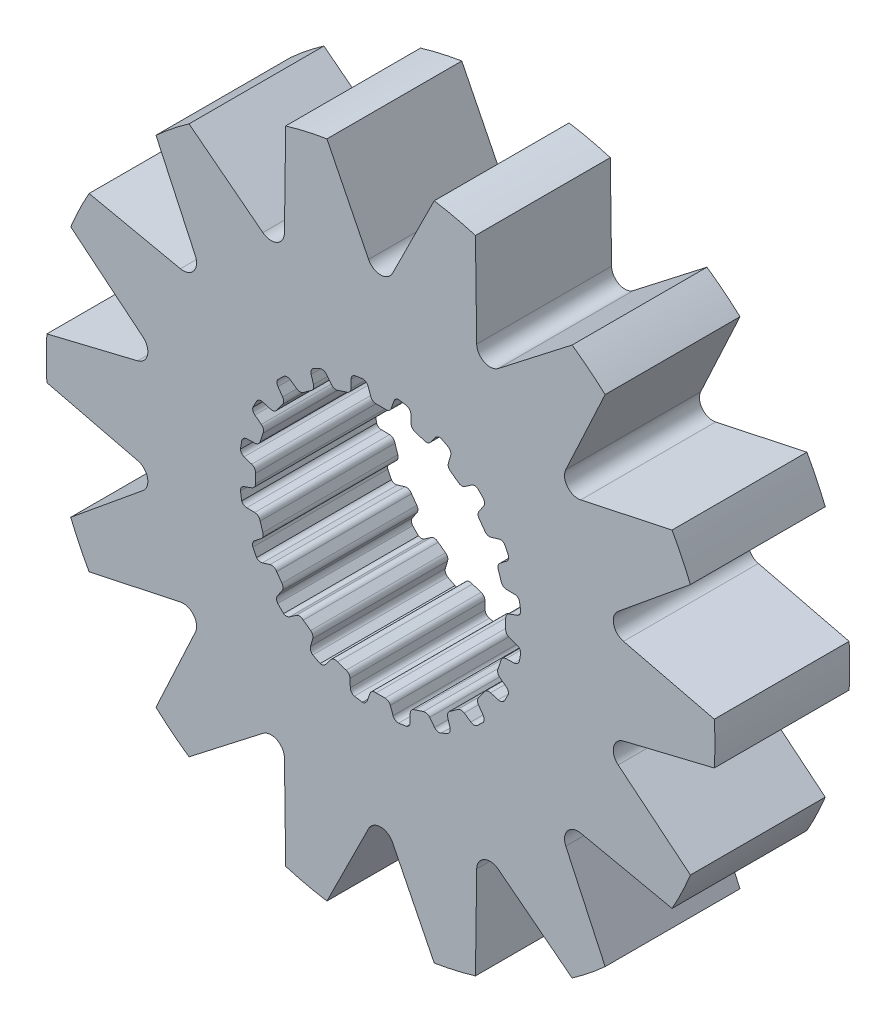
from build123d import *

# Parameters (mm, degrees)
SKETCH1_R           = 7.934400625
BOSS_EXTRUDE1_DEPTH = 1.6002
CUT_EXTRUDE1_DEPTH  = 3.2004


with BuildPart() as part:
    # Sketch1 → Boss-Extrude1 (new body, symmetric)
    with BuildSketch(Plane.XY):
        Circle(SKETCH1_R)
        with BuildLine():
            Line((-0.106949245, 2.969874934), (0.106949245, 2.969874934))
            ThreePointArc((0.106949245, 2.969874934), (0.196343213, 2.986924176), (0.253739238, 3.057547504))
            Line((0.253739238, 3.057547504), (0.315888147, 3.237526941))
            ThreePointArc((0.315888147, 3.237526941), (0.359032156, 3.298322911), (0.4281449, 3.326269005))
            Line((0.4281449, 3.326269005), (0.620027588, 3.2937547))
            ThreePointArc((0.620027588, 3.2937547), (0.689621142, 3.24802576), (0.718272212, 3.169836791))
            Line((0.718272212, 3.169836791), (0.724389167, 2.979527391))
            ThreePointArc((0.724389167, 2.979527391), (0.750934762, 2.9040661), (0.816027049, 2.857568043))
            Line((0.816027049, 2.857568043), (1.019456602, 2.791469774))
            ThreePointArc((1.019456602, 2.791469774), (1.109743823, 2.780060312), (1.186154496, 2.829490741))
            Line((1.186154496, 2.829490741), (1.300878326, 2.981456288))
            ThreePointArc((1.300878326, 2.981456288), (1.360697704, 3.02594446), (1.435063648, 3.031165762))
            Line((1.435063648, 3.031165762), (1.607507455, 2.940947809))
            ThreePointArc((1.607507455, 2.940947809), (1.659563839, 2.875951412), (1.662650905, 2.792735615))
            Line((1.662650905, 2.792735615), (1.609659636, 2.609850378))
            ThreePointArc((1.609659636, 2.609850378), (1.611587176, 2.529879385), (1.659124931, 2.465542482))
            Line((1.659124931, 2.465542482), (1.832172444, 2.339816104))
            ThreePointArc((1.832172444, 2.339816104), (1.914514976, 2.301064775), (2.002460687, 2.32446371))
            Line((2.002460687, 2.32446371), (2.158529469, 2.433539921))
            ThreePointArc((2.158529469, 2.433539921), (2.229168681, 2.457365482), (2.301508367, 2.439350895))
            Line((2.301508367, 2.439350895), (2.437633293, 2.300260456))
            ThreePointArc((2.437633293, 2.300260456), (2.467056864, 2.222358901), (2.444277744, 2.14226202))
            Line((2.444277744, 2.14226202), (2.337365406, 1.984703026))
            ThreePointArc((2.337365406, 1.984703026), (2.314486209, 1.908050449), (2.339816104, 1.832172444))
            Line((2.339816104, 1.832172444), (2.465542482, 1.659124931))
            ThreePointArc((2.465542482, 1.659124931), (2.531880064, 1.596824985), (2.622752074, 1.591901975))
            Line((2.622752074, 1.591901975), (2.804888709, 1.64741171))
            ThreePointArc((2.804888709, 1.64741171), (2.879433095, 1.648242449), (2.942665411, 1.608755366))
            Line((2.942665411, 1.608755366), (3.0291466, 1.434407582))
            ThreePointArc((3.0291466, 1.434407582), (3.033057175, 1.351226417), (2.986641646, 1.282088892))
            Line((2.986641646, 1.282088892), (2.836273564, 1.165279113))
            ThreePointArc((2.836273564, 1.165279113), (2.790827206, 1.099448241), (2.791469774, 1.019456602))
            Line((2.791469774, 1.019456602), (2.857568043, 0.816027049))
            ThreePointArc((2.857568043, 0.816027049), (2.901407091, 0.736276839), (2.986310214, 0.703513784))
            Line((2.986310214, 0.703513784), (3.1766859, 0.700023363))
            ThreePointArc((3.1766859, 0.700023363), (3.247838536, 0.677777961), (3.295773863, 0.620683653))
            Line((3.295773863, 0.620683653), (3.324145932, 0.4281449))
            ThreePointArc((3.324145932, 0.4281449), (3.302160717, 0.347826477), (3.236652255, 0.29641597))
            Line((3.236652255, 0.29641597), (3.057547504, 0.231789562))
            ThreePointArc((3.057547504, 0.231789562), (2.993982591, 0.183224379), (2.969874934, 0.106949245))
            Line((2.969874934, 0.106949245), (2.969874934, -0.106949245))
            ThreePointArc((2.969874934, -0.106949245), (2.986924176, -0.196343213), (3.057547504, -0.253739238))
            Line((3.057547504, -0.253739238), (3.237526941, -0.315888147))
            ThreePointArc((3.237526941, -0.315888147), (3.298322911, -0.359032156), (3.326269005, -0.4281449))
            Line((3.326269005, -0.4281449), (3.2937547, -0.620027588))
            ThreePointArc((3.2937547, -0.620027588), (3.24802576, -0.689621142), (3.169836791, -0.718272212))
            Line((3.169836791, -0.718272212), (2.979527391, -0.724389167))
            ThreePointArc((2.979527391, -0.724389167), (2.9040661, -0.750934762), (2.857568043, -0.816027049))
            Line((2.857568043, -0.816027049), (2.791469774, -1.019456602))
            ThreePointArc((2.791469774, -1.019456602), (2.780060312, -1.109743823), (2.829490741, -1.186154496))
            Line((2.829490741, -1.186154496), (2.981456288, -1.300878326))
            ThreePointArc((2.981456288, -1.300878326), (3.02594446, -1.360697704), (3.031165762, -1.435063648))
            Line((3.031165762, -1.435063648), (2.940947809, -1.607507455))
            ThreePointArc((2.940947809, -1.607507455), (2.875951412, -1.659563839), (2.792735615, -1.662650905))
            Line((2.792735615, -1.662650905), (2.609850378, -1.609659636))
            ThreePointArc((2.609850378, -1.609659636), (2.529879385, -1.611587176), (2.465542482, -1.659124931))
            Line((2.465542482, -1.659124931), (2.339816104, -1.832172444))
            ThreePointArc((2.339816104, -1.832172444), (2.301064775, -1.914514976), (2.32446371, -2.002460687))
            Line((2.32446371, -2.002460687), (2.433539921, -2.158529469))
            ThreePointArc((2.433539921, -2.158529469), (2.457365482, -2.229168681), (2.439350895, -2.301508367))
            Line((2.439350895, -2.301508367), (2.300260456, -2.437633293))
            ThreePointArc((2.300260456, -2.437633293), (2.222358901, -2.467056864), (2.14226202, -2.444277744))
            Line((2.14226202, -2.444277744), (1.984703026, -2.337365406))
            ThreePointArc((1.984703026, -2.337365406), (1.908050449, -2.314486209), (1.832172444, -2.339816104))
            Line((1.832172444, -2.339816104), (1.659124931, -2.465542482))
            ThreePointArc((1.659124931, -2.465542482), (1.596824985, -2.531880064), (1.591901975, -2.622752074))
            Line((1.591901975, -2.622752074), (1.64741171, -2.804888709))
            ThreePointArc((1.64741171, -2.804888709), (1.648242449, -2.879433095), (1.608755366, -2.942665411))
            Line((1.608755366, -2.942665411), (1.434407582, -3.0291466))
            ThreePointArc((1.434407582, -3.0291466), (1.351226417, -3.033057175), (1.282088892, -2.986641646))
            Line((1.282088892, -2.986641646), (1.165279113, -2.836273564))
            ThreePointArc((1.165279113, -2.836273564), (1.099448241, -2.790827206), (1.019456602, -2.791469774))
            Line((1.019456602, -2.791469774), (0.816027049, -2.857568043))
            ThreePointArc((0.816027049, -2.857568043), (0.736276839, -2.901407091), (0.703513784, -2.986310214))
            Line((0.703513784, -2.986310214), (0.700023363, -3.1766859))
            ThreePointArc((0.700023363, -3.1766859), (0.677777961, -3.247838536), (0.620683653, -3.295773863))
            Line((0.620683653, -3.295773863), (0.4281449, -3.324145932))
            ThreePointArc((0.4281449, -3.324145932), (0.347826477, -3.302160717), (0.29641597, -3.236652255))
            Line((0.29641597, -3.236652255), (0.231789562, -3.057547504))
            ThreePointArc((0.231789562, -3.057547504), (0.183224379, -2.993982591), (0.106949245, -2.969874934))
            Line((0.106949245, -2.969874934), (-0.106949245, -2.969874934))
            ThreePointArc((-0.106949245, -2.969874934), (-0.196343213, -2.986924176), (-0.253739238, -3.057547504))
            Line((-0.253739238, -3.057547504), (-0.315888147, -3.237526941))
            ThreePointArc((-0.315888147, -3.237526941), (-0.359032156, -3.298322911), (-0.4281449, -3.326269005))
            Line((-0.4281449, -3.326269005), (-0.620027588, -3.2937547))
            ThreePointArc((-0.620027588, -3.2937547), (-0.689621142, -3.24802576), (-0.718272212, -3.169836791))
            Line((-0.718272212, -3.169836791), (-0.724389167, -2.979527391))
            ThreePointArc((-0.724389167, -2.979527391), (-0.750934762, -2.9040661), (-0.816027049, -2.857568043))
            Line((-0.816027049, -2.857568043), (-1.019456602, -2.791469774))
            ThreePointArc((-1.019456602, -2.791469774), (-1.109743823, -2.780060312), (-1.186154496, -2.829490741))
            Line((-1.186154496, -2.829490741), (-1.300878326, -2.981456288))
            ThreePointArc((-1.300878326, -2.981456288), (-1.360697704, -3.02594446), (-1.435063648, -3.031165762))
            Line((-1.435063648, -3.031165762), (-1.607507455, -2.940947809))
            ThreePointArc((-1.607507455, -2.940947809), (-1.659563839, -2.875951412), (-1.662650905, -2.792735615))
            Line((-1.662650905, -2.792735615), (-1.609659636, -2.609850378))
            ThreePointArc((-1.609659636, -2.609850378), (-1.611587176, -2.529879385), (-1.659124931, -2.465542482))
            Line((-1.659124931, -2.465542482), (-1.832172444, -2.339816104))
            ThreePointArc((-1.832172444, -2.339816104), (-1.914514976, -2.301064775), (-2.002460687, -2.32446371))
            Line((-2.002460687, -2.32446371), (-2.158529469, -2.433539921))
            ThreePointArc((-2.158529469, -2.433539921), (-2.229168681, -2.457365482), (-2.301508367, -2.439350895))
            Line((-2.301508367, -2.439350895), (-2.437633293, -2.300260456))
            ThreePointArc((-2.437633293, -2.300260456), (-2.467056864, -2.222358901), (-2.444277744, -2.14226202))
            Line((-2.444277744, -2.14226202), (-2.337365406, -1.984703026))
            ThreePointArc((-2.337365406, -1.984703026), (-2.314486209, -1.908050449), (-2.339816104, -1.832172444))
            Line((-2.339816104, -1.832172444), (-2.465542482, -1.659124931))
            ThreePointArc((-2.465542482, -1.659124931), (-2.531880064, -1.596824985), (-2.622752074, -1.591901975))
            Line((-2.622752074, -1.591901975), (-2.804888709, -1.64741171))
            ThreePointArc((-2.804888709, -1.64741171), (-2.879433095, -1.648242449), (-2.942665411, -1.608755366))
            Line((-2.942665411, -1.608755366), (-3.0291466, -1.434407582))
            ThreePointArc((-3.0291466, -1.434407582), (-3.033057175, -1.351226417), (-2.986641646, -1.282088892))
            Line((-2.986641646, -1.282088892), (-2.836273564, -1.165279113))
            ThreePointArc((-2.836273564, -1.165279113), (-2.790827206, -1.099448241), (-2.791469774, -1.019456602))
            Line((-2.791469774, -1.019456602), (-2.857568043, -0.816027049))
            ThreePointArc((-2.857568043, -0.816027049), (-2.901407091, -0.736276839), (-2.986310214, -0.703513784))
            Line((-2.986310214, -0.703513784), (-3.1766859, -0.700023363))
            ThreePointArc((-3.1766859, -0.700023363), (-3.247838536, -0.677777961), (-3.295773863, -0.620683653))
            Line((-3.295773863, -0.620683653), (-3.324145932, -0.4281449))
            ThreePointArc((-3.324145932, -0.4281449), (-3.302160717, -0.347826477), (-3.236652255, -0.29641597))
            Line((-3.236652255, -0.29641597), (-3.057547504, -0.231789562))
            ThreePointArc((-3.057547504, -0.231789562), (-2.993982591, -0.183224379), (-2.969874934, -0.106949245))
            Line((-2.969874934, -0.106949245), (-2.969874934, 0.106949245))
            ThreePointArc((-2.969874934, 0.106949245), (-2.986924176, 0.196343213), (-3.057547504, 0.253739238))
            Line((-3.057547504, 0.253739238), (-3.237526941, 0.315888147))
            ThreePointArc((-3.237526941, 0.315888147), (-3.298322911, 0.359032156), (-3.326269005, 0.4281449))
            Line((-3.326269005, 0.4281449), (-3.2937547, 0.620027588))
            ThreePointArc((-3.2937547, 0.620027588), (-3.24802576, 0.689621142), (-3.169836791, 0.718272212))
            Line((-3.169836791, 0.718272212), (-2.979527391, 0.724389167))
            ThreePointArc((-2.979527391, 0.724389167), (-2.9040661, 0.750934762), (-2.857568043, 0.816027049))
            Line((-2.857568043, 0.816027049), (-2.791469774, 1.019456602))
            ThreePointArc((-2.791469774, 1.019456602), (-2.780060312, 1.109743823), (-2.829490741, 1.186154496))
            Line((-2.829490741, 1.186154496), (-2.981456288, 1.300878326))
            ThreePointArc((-2.981456288, 1.300878326), (-3.02594446, 1.360697704), (-3.031165762, 1.435063648))
            Line((-3.031165762, 1.435063648), (-2.940947809, 1.607507455))
            ThreePointArc((-2.940947809, 1.607507455), (-2.875951412, 1.659563839), (-2.792735615, 1.662650905))
            Line((-2.792735615, 1.662650905), (-2.609850378, 1.609659636))
            ThreePointArc((-2.609850378, 1.609659636), (-2.529879385, 1.611587176), (-2.465542482, 1.659124931))
            Line((-2.465542482, 1.659124931), (-2.339816104, 1.832172444))
            ThreePointArc((-2.339816104, 1.832172444), (-2.301064775, 1.914514976), (-2.32446371, 2.002460687))
            Line((-2.32446371, 2.002460687), (-2.433539921, 2.158529469))
            ThreePointArc((-2.433539921, 2.158529469), (-2.457365482, 2.229168681), (-2.439350895, 2.301508367))
            Line((-2.439350895, 2.301508367), (-2.300260456, 2.437633293))
            ThreePointArc((-2.300260456, 2.437633293), (-2.222358901, 2.467056864), (-2.14226202, 2.444277744))
            Line((-2.14226202, 2.444277744), (-1.984703026, 2.337365406))
            ThreePointArc((-1.984703026, 2.337365406), (-1.908050449, 2.314486209), (-1.832172444, 2.339816104))
            Line((-1.832172444, 2.339816104), (-1.659124931, 2.465542482))
            ThreePointArc((-1.659124931, 2.465542482), (-1.596824985, 2.531880064), (-1.591901975, 2.622752074))
            Line((-1.591901975, 2.622752074), (-1.64741171, 2.804888709))
            ThreePointArc((-1.64741171, 2.804888709), (-1.648242449, 2.879433095), (-1.608755366, 2.942665411))
            Line((-1.608755366, 2.942665411), (-1.434407582, 3.0291466))
            ThreePointArc((-1.434407582, 3.0291466), (-1.351226417, 3.033057175), (-1.282088892, 2.986641646))
            Line((-1.282088892, 2.986641646), (-1.165279113, 2.836273564))
            ThreePointArc((-1.165279113, 2.836273564), (-1.099448241, 2.790827206), (-1.019456602, 2.791469774))
            Line((-1.019456602, 2.791469774), (-0.816027049, 2.857568043))
            ThreePointArc((-0.816027049, 2.857568043), (-0.736276839, 2.901407091), (-0.703513784, 2.986310214))
            Line((-0.703513784, 2.986310214), (-0.700023363, 3.1766859))
            ThreePointArc((-0.700023363, 3.1766859), (-0.677777961, 3.247838536), (-0.620683653, 3.295773863))
            Line((-0.620683653, 3.295773863), (-0.4281449, 3.324145932))
            ThreePointArc((-0.4281449, 3.324145932), (-0.347826477, 3.302160717), (-0.29641597, 3.236652255))
            Line((-0.29641597, 3.236652255), (-0.231789562, 3.057547504))
            ThreePointArc((-0.231789562, 3.057547504), (-0.183224379, 2.993982591), (-0.106949245, 2.969874934))
        make_face(mode=Mode.SUBTRACT)
    extrude(amount=BOSS_EXTRUDE1_DEPTH, both=True)

    # Sketch2 → Cut-Extrude1 (cut)
    with BuildSketch(Plane.XY.offset(1.6002)):
        with BuildLine():
            Line((-1.272861916, 7.831636854), (-0.284158084, 5.848036698))
            ThreePointArc((-0.284158084, 5.848036698), (0, 5.672171908), (0.284158084, 5.848036698))
            Line((0.284158084, 5.848036698), (1.272861916, 7.831636854))
            ThreePointArc((1.272861916, 7.831636854), (0, 7.934400625), (-1.272861916, 7.831636854))
        make_face()
        with BuildLine():
            Line((4.544828841, 6.503786903), (2.793385616, 5.145607431))
            ThreePointArc((2.793385616, 5.145607431), (2.461063157, 5.110450303), (2.281350442, 5.392190575))
            Line((2.281350442, 5.392190575), (2.251210922, 7.608335078))
            ThreePointArc((2.251210922, 7.608335078), (3.442607411, 7.148647948), (4.544828841, 6.503786903))
        make_face()
        with BuildLine():
            Line((6.916636676, 3.887782192), (4.749348869, 3.424027506))
            ThreePointArc((4.749348869, 3.424027506), (4.434682572, 3.536541339), (4.395009534, 3.868354978))
            Line((4.395009534, 3.868354978), (5.329403828, 5.878109229))
            ThreePointArc((5.329403828, 5.878109229), (6.203364203, 4.947017873), (6.916636676, 3.887782192))
        make_face()
        with BuildLine():
            Line((7.91851979, 0.501754537), (5.764645331, 1.02427694))
            ThreePointArc((5.764645331, 1.02427694), (5.529958716, 1.262176991), (5.638183086, 1.578344235))
            Line((5.638183086, 1.578344235), (7.352042945, 2.983651757))
            ThreePointArc((7.352042945, 2.983651757), (7.735468636, 1.765570237), (7.91851979, 0.501754537))
        make_face()
        with BuildLine():
            Line((7.352042945, -2.983651757), (5.638183086, -1.578344235))
            ThreePointArc((5.638183086, -1.578344235), (5.529958716, -1.262176991), (5.764645331, -1.02427694))
            Line((5.764645331, -1.02427694), (7.91851979, -0.501754537))
            ThreePointArc((7.91851979, -0.501754537), (7.735468636, -1.765570237), (7.352042945, -2.983651757))
        make_face()
        with BuildLine():
            Line((5.329403828, -5.878109229), (4.395009534, -3.868354978))
            ThreePointArc((4.395009534, -3.868354978), (4.434682572, -3.536541339), (4.749348869, -3.424027506))
            Line((4.749348869, -3.424027506), (6.916636676, -3.887782192))
            ThreePointArc((6.916636676, -3.887782192), (6.203364203, -4.947017873), (5.329403828, -5.878109229))
        make_face()
        with BuildLine():
            Line((2.251210922, -7.608335078), (2.281350442, -5.392190575))
            ThreePointArc((2.281350442, -5.392190575), (2.461063157, -5.110450303), (2.793385616, -5.145607431))
            Line((2.793385616, -5.145607431), (4.544828841, -6.503786903))
            ThreePointArc((4.544828841, -6.503786903), (3.442607411, -7.148647948), (2.251210922, -7.608335078))
        make_face()
        with BuildLine():
            Line((-1.272861916, -7.831636854), (-0.284158084, -5.848036698))
            ThreePointArc((-0.284158084, -5.848036698), (0, -5.672171908), (0.284158084, -5.848036698))
            Line((0.284158084, -5.848036698), (1.272861916, -7.831636854))
            ThreePointArc((1.272861916, -7.831636854), (0, -7.934400625), (-1.272861916, -7.831636854))
        make_face()
        with BuildLine():
            Line((-4.544828841, -6.503786903), (-2.793385616, -5.145607431))
            ThreePointArc((-2.793385616, -5.145607431), (-2.461063157, -5.110450303), (-2.281350442, -5.392190575))
            Line((-2.281350442, -5.392190575), (-2.251210922, -7.608335078))
            ThreePointArc((-2.251210922, -7.608335078), (-3.442607411, -7.148647948), (-4.544828841, -6.503786903))
        make_face()
        with BuildLine():
            Line((-6.916636676, -3.887782192), (-4.749348869, -3.424027506))
            ThreePointArc((-4.749348869, -3.424027506), (-4.434682572, -3.536541339), (-4.395009534, -3.868354978))
            Line((-4.395009534, -3.868354978), (-5.329403828, -5.878109229))
            ThreePointArc((-5.329403828, -5.878109229), (-6.203364203, -4.947017873), (-6.916636676, -3.887782192))
        make_face()
        with BuildLine():
            Line((-7.91851979, -0.501754537), (-5.764645331, -1.02427694))
            ThreePointArc((-5.764645331, -1.02427694), (-5.529958716, -1.262176991), (-5.638183086, -1.578344235))
            Line((-5.638183086, -1.578344235), (-7.352042945, -2.983651757))
            ThreePointArc((-7.352042945, -2.983651757), (-7.735468636, -1.765570237), (-7.91851979, -0.501754537))
        make_face()
        with BuildLine():
            Line((-7.352042945, 2.983651757), (-5.638183086, 1.578344235))
            ThreePointArc((-5.638183086, 1.578344235), (-5.529958716, 1.262176991), (-5.764645331, 1.02427694))
            Line((-5.764645331, 1.02427694), (-7.91851979, 0.501754537))
            ThreePointArc((-7.91851979, 0.501754537), (-7.735468636, 1.765570237), (-7.352042945, 2.983651757))
        make_face()
        with BuildLine():
            Line((-5.329403828, 5.878109229), (-4.395009534, 3.868354978))
            ThreePointArc((-4.395009534, 3.868354978), (-4.434682572, 3.536541339), (-4.749348869, 3.424027506))
            Line((-4.749348869, 3.424027506), (-6.916636676, 3.887782192))
            ThreePointArc((-6.916636676, 3.887782192), (-6.203364203, 4.947017873), (-5.329403828, 5.878109229))
        make_face()
        with BuildLine():
            Line((-2.251210922, 7.608335078), (-2.281350442, 5.392190575))
            ThreePointArc((-2.281350442, 5.392190575), (-2.461063157, 5.110450303), (-2.793385616, 5.145607431))
            Line((-2.793385616, 5.145607431), (-4.544828841, 6.503786903))
            ThreePointArc((-4.544828841, 6.503786903), (-3.442607411, 7.148647948), (-2.251210922, 7.608335078))
        make_face()
    extrude(amount=-CUT_EXTRUDE1_DEPTH, mode=Mode.SUBTRACT)


solid = part.part
